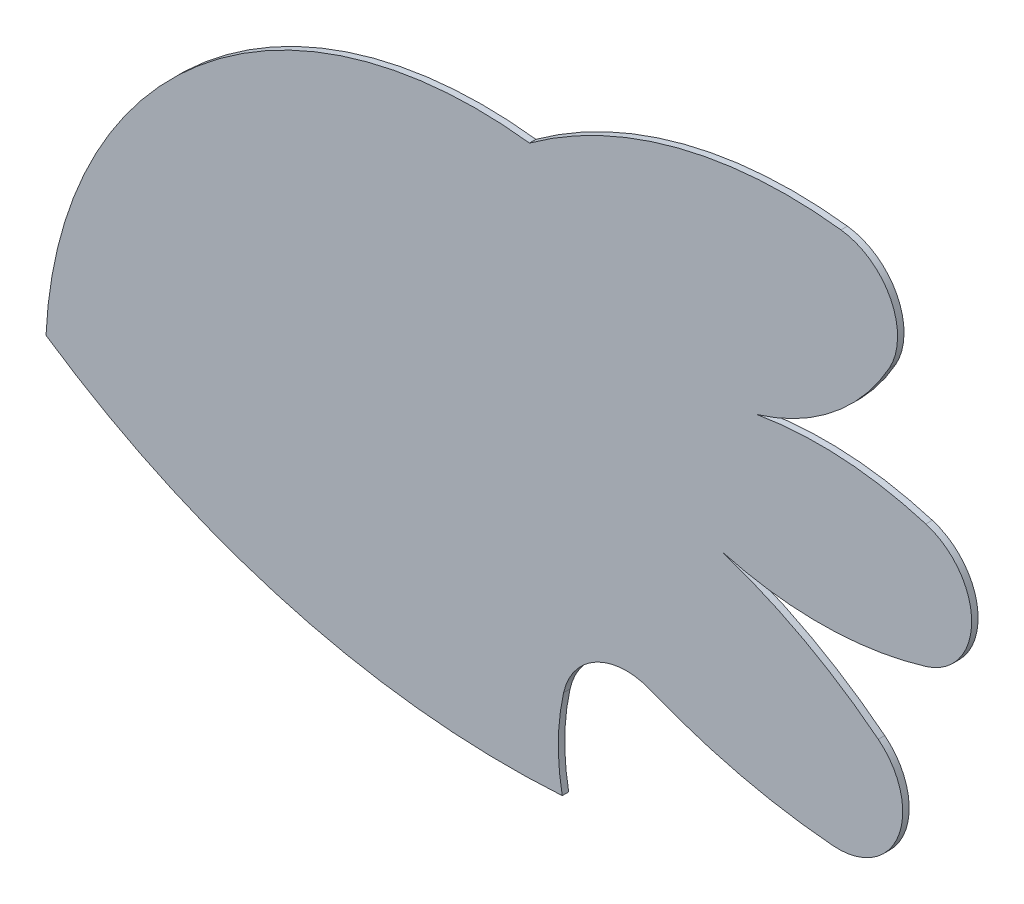
from build123d import *

# Parameters (mm, degrees)
SALIENTE_EXTRUIR1_DEPTH = 0.1


with BuildPart() as part:
    # Model → Saliente-Extruir1 (new body)
    with BuildSketch(Plane.XY):
        with BuildLine():
            ThreePointArc((22.540248989, 13.854945853), (26.36224915, 12.09625195), (30.548359243, 11.675334187))
            ThreePointArc((30.548359243, 11.675334187), (30.487312629, 12.373336734), (30.5695137, 13.069165182))
            ThreePointArc((30.5695137, 13.069165182), (31.081390856, 13.736758239), (31.921654238, 13.777454212))
            ThreePointArc((31.921654238, 13.777454212), (33.309090368, 13.333130187), (34.7477202, 13.103462905))
            ThreePointArc((34.7477202, 13.103462905), (35.76012095, 13.732496208), (35.451331706, 14.883707473))
            ThreePointArc((35.451331706, 14.883707473), (34.302777703, 15.641386071), (33.040248989, 16.188445853))
            ThreePointArc((33.040248989, 16.188445853), (34.617609881, 15.988093646), (36.188952789, 16.231177692))
            ThreePointArc((36.188952789, 16.231177692), (36.899751011, 17.188445853), (36.188952789, 18.145714014))
            ThreePointArc((36.188952789, 18.145714014), (34.888660423, 18.378666365), (33.569660753, 18.306092912))
            ThreePointArc((33.569660753, 18.306092912), (34.755020368, 18.932581608), (35.621884252, 19.955378023))
            ThreePointArc((35.621884252, 19.955378023), (35.642787011, 20.89656979), (34.872667415, 21.438044328))
            ThreePointArc((34.872667415, 21.438044328), (32.337672311, 21.27261115), (30.040248989, 20.188445853))
            ThreePointArc((30.040248989, 20.188445853), (24.906113256, 18.660760825), (22.540248989, 13.854945853))
        make_face()
    extrude(amount=SALIENTE_EXTRUIR1_DEPTH)


solid = part.part
